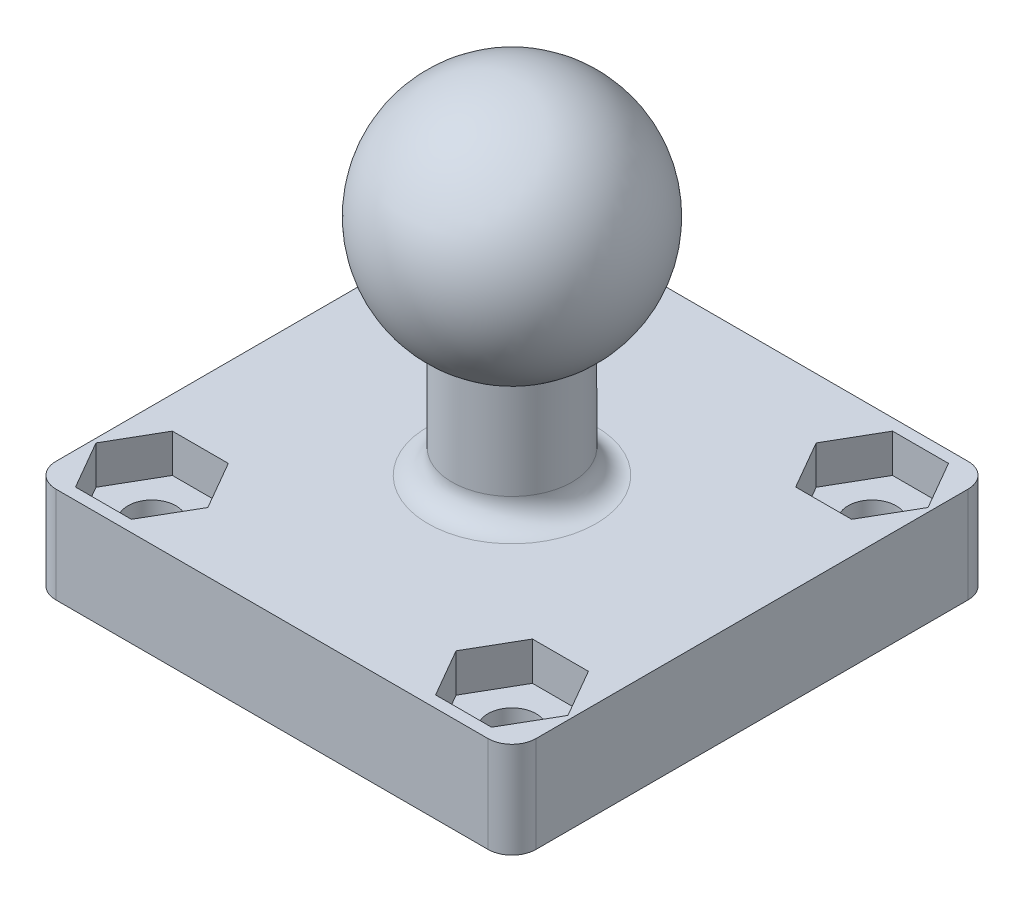
from build123d import *

# Parameters (mm, degrees)
ESQUISSE2_W             = 20
ESQUISSE2_H             = 20
BOSS_EXTRU_1_DEPTH      = 4
ENL_V_MAT_EXTRU_1_REACH = 6
ESQUISSE3_R             = 1
CONG_1_R                = 1
ENL_V_MAT_EXTRU_2_DEPTH = 1.6


with BuildPart() as part:
    # Esquisse1 → Révolution1 (revolve)
    with BuildSketch(Plane.XY):
        with BuildLine():
            Line((-2.5, -4.330127019), (-2.5, -9.330127019))
            Line((-2.5, -9.330127019), (0, -9.330127019))
            Line((0, -9.330127019), (0, 5))
            ThreePointArc((0, 5), (-4.829629131, 1.294095226), (-2.5, -4.330127019))
        make_face()
    revolve(axis=Axis((0, -9.330127019, 0), (0, 1, 0)))

    # Esquisse2 → Boss.-Extru.1 (add)
    with BuildSketch(Plane.XZ.offset(9.330127019)):
        Rectangle(ESQUISSE2_W, ESQUISSE2_H)
    extrude(amount=BOSS_EXTRU_1_DEPTH)

    # Esquisse3 → Enlèv. mat.-Extru.1 (cut, up to next)
    with BuildSketch(Plane(origin=(0, -9.330127019, 0), x_dir=(1, 0, 0), z_dir=(0, 1, 0)), mode=Mode.PRIVATE) as enl_v_mat_extru_1_sk1:
        with Locations(Location((7.5, -7.5, 0), (0, 0, 180))):  # turned: the seam where the file's is
            Circle(ESQUISSE3_R)
    enl_v_mat_extru_1_tool1 = extrude(enl_v_mat_extru_1_sk1.sketch, amount=-ENL_V_MAT_EXTRU_1_REACH, mode=Mode.PRIVATE) & part.part
    add(enl_v_mat_extru_1_tool1.solids().sort_by_distance((7.5, -9.330127, 7.5))[0], mode=Mode.SUBTRACT)
    # Esquisse3 → Enlèv. mat.-Extru.1 (cut, up to next)
    with BuildSketch(Plane(origin=(0, -9.330127019, 0), x_dir=(1, 0, 0), z_dir=(0, 1, 0)), mode=Mode.PRIVATE) as enl_v_mat_extru_1_sk2:
        with Locations(Location((7.5, 7.5, 0), (0, 0, 180))):  # turned: the seam where the file's is
            Circle(ESQUISSE3_R)
    enl_v_mat_extru_1_tool2 = extrude(enl_v_mat_extru_1_sk2.sketch, amount=-ENL_V_MAT_EXTRU_1_REACH, mode=Mode.PRIVATE) & part.part
    add(enl_v_mat_extru_1_tool2.solids().sort_by_distance((7.5, -9.330127, -7.5))[0], mode=Mode.SUBTRACT)
    # Esquisse3 → Enlèv. mat.-Extru.1 (cut, up to next)
    with BuildSketch(Plane(origin=(0, -9.330127019, 0), x_dir=(1, 0, 0), z_dir=(0, 1, 0)), mode=Mode.PRIVATE) as enl_v_mat_extru_1_sk3:
        with Locations(Location((-7.5, 7.5, 0), (0, 0, 180))):  # turned: the seam where the file's is
            Circle(ESQUISSE3_R)
    enl_v_mat_extru_1_tool3 = extrude(enl_v_mat_extru_1_sk3.sketch, amount=-ENL_V_MAT_EXTRU_1_REACH, mode=Mode.PRIVATE) & part.part
    add(enl_v_mat_extru_1_tool3.solids().sort_by_distance((-7.5, -9.330127, -7.5))[0], mode=Mode.SUBTRACT)
    # Esquisse3 → Enlèv. mat.-Extru.1 (cut, up to next)
    with BuildSketch(Plane(origin=(0, -9.330127019, 0), x_dir=(1, 0, 0), z_dir=(0, 1, 0)), mode=Mode.PRIVATE) as enl_v_mat_extru_1_sk4:
        with Locations(Location((-7.5, -7.5, 0), (0, 0, 180))):  # turned: the seam where the file's is
            Circle(ESQUISSE3_R)
    enl_v_mat_extru_1_tool4 = extrude(enl_v_mat_extru_1_sk4.sketch, amount=-ENL_V_MAT_EXTRU_1_REACH, mode=Mode.PRIVATE) & part.part
    add(enl_v_mat_extru_1_tool4.solids().sort_by_distance((-7.5, -9.330127, 7.5))[0], mode=Mode.SUBTRACT)

    # Congé1
    cong_1_edges = [part.edges().sort_by_distance(p)[0] for p in [
        (-10, -11.330127019, -10),
        (10, -11.330127019, -10),
        (10, -11.330127019, 10),
        (2.5, -9.330127019, 0),
        (-10, -11.330127019, 10),
    ]]
    fillet(cong_1_edges, radius=CONG_1_R)

    # Esquisse4 → Enlèv. mat.-Extru.2 (cut)
    with BuildSketch(Plane(origin=(0, -9.330127019, 0), x_dir=(1, 0, 0), z_dir=(0, 1, 0))):
        Polygon((-6.335, -5.482160809), (-8.665, -5.482160809), (-9.83, -7.5), (-8.665, -9.517839191), (-6.335, -9.517839191), (-5.17, -7.5), align=None)
        Polygon((9.83, -7.5), (8.665, -5.482160809), (6.335, -5.482160809), (5.17, -7.5), (6.335, -9.517839191), (8.665, -9.517839191), align=None)
        Polygon((8.665, 5.482160809), (9.83, 7.5), (8.665, 9.517839191), (6.335, 9.517839191), (5.17, 7.5), (6.335, 5.482160809), align=None)
        Polygon((-5.17, 7.5), (-6.335, 9.517839191), (-8.665, 9.517839191), (-9.83, 7.5), (-8.665, 5.482160809), (-6.335, 5.482160809), align=None)
    extrude(amount=-ENL_V_MAT_EXTRU_2_DEPTH, mode=Mode.SUBTRACT)


solid = part.part
